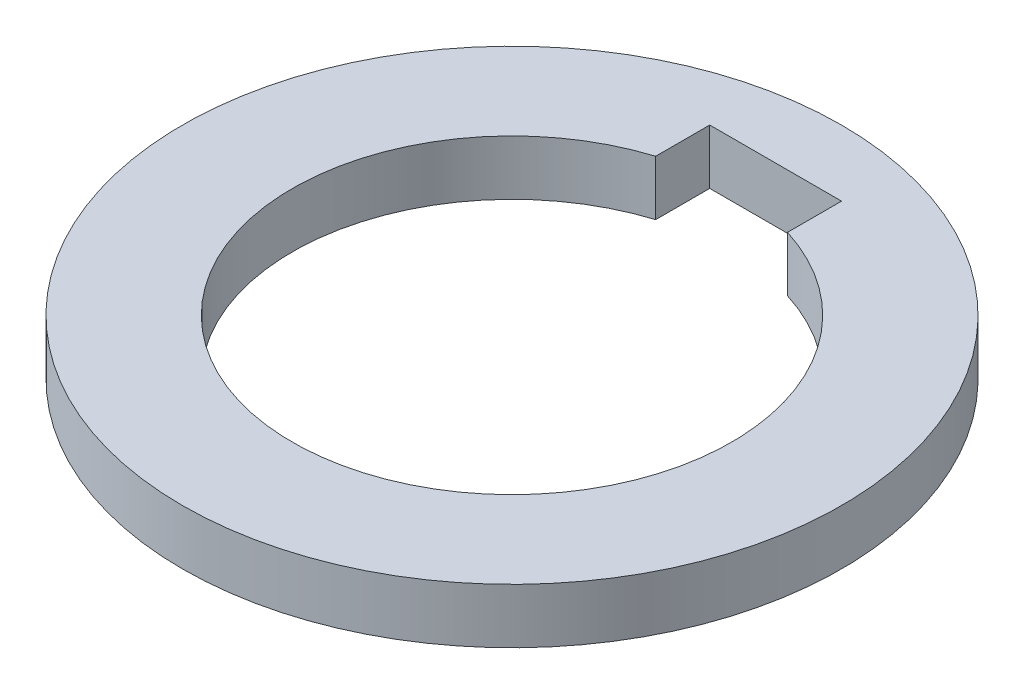
from build123d import *

# Parameters (mm, degrees)
SKIZZE1_R                       = 30
AUFSATZ_LINEAR_AUSTRAGEN1_DEPTH = 5
SKIZZE1_3_R                     = 20
SCHNITT_LINEAR_AUSTRAGEN1_DEPTH = 5
SCHNITT_LINEAR_AUSTRAGEN2_DEPTH = 5


with BuildPart() as part:
    # Skizze1 → Aufsatz-Linear austragen1 (new body)
    with BuildSketch(Plane(origin=(0, 0, 0), x_dir=(1, 0, 0), z_dir=(0, 1, 0))):
        with Locations(Location((0, 0, 0), (0, 0, 270))):  # turned: the seam where the file's is
            Circle(SKIZZE1_R)
    extrude(amount=AUFSATZ_LINEAR_AUSTRAGEN1_DEPTH)

    # Skizze1_3 → Schnitt-Linear austragen1 (cut)
    with BuildSketch(Plane(origin=(0, 0, 0), x_dir=(1, 0, 0), z_dir=(0, 1, 0))):
        with Locations(Location((0, 0, 0), (0, 0, 270))):  # turned: the seam where the file's is
            Circle(SKIZZE1_3_R)
    extrude(amount=SCHNITT_LINEAR_AUSTRAGEN1_DEPTH, mode=Mode.SUBTRACT)

    # Skizze1_4 → Schnitt-Linear austragen2 (cut)
    with BuildSketch(Plane(origin=(0, 0, 0), x_dir=(1, 0, 0), z_dir=(0, 1, 0))):
        with BuildLine():
            ThreePointArc((-6, 19.078784028), (0, 20), (6, 19.078784028))
            Line((6, 19.078784028), (6, 24))
            Line((6, 24), (-6, 24))
            Line((-6, 24), (-6, 19.078784028))
        make_face()
    extrude(amount=SCHNITT_LINEAR_AUSTRAGEN2_DEPTH, mode=Mode.SUBTRACT)


solid = part.part
